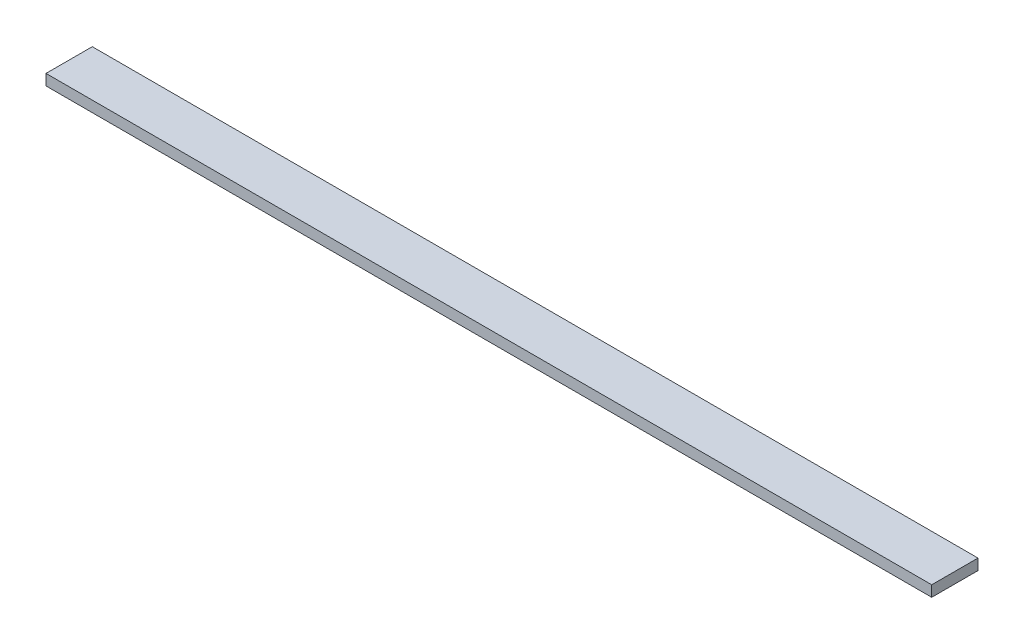
from build123d import *

# Parameters (mm, degrees)
SKETCH1_W           = 972.312
SKETCH1_H           = 50.8
BOSS_EXTRUDE1_DEPTH = 11.938


with BuildPart() as part:
    # Sketch1 → Boss-Extrude1 (new body)
    with BuildSketch(Plane(origin=(0, 0, 0), x_dir=(1, 0, 0), z_dir=(0, 1, 0))):
        Rectangle(SKETCH1_W, SKETCH1_H)
    extrude(amount=BOSS_EXTRUDE1_DEPTH)


solid = part.part
